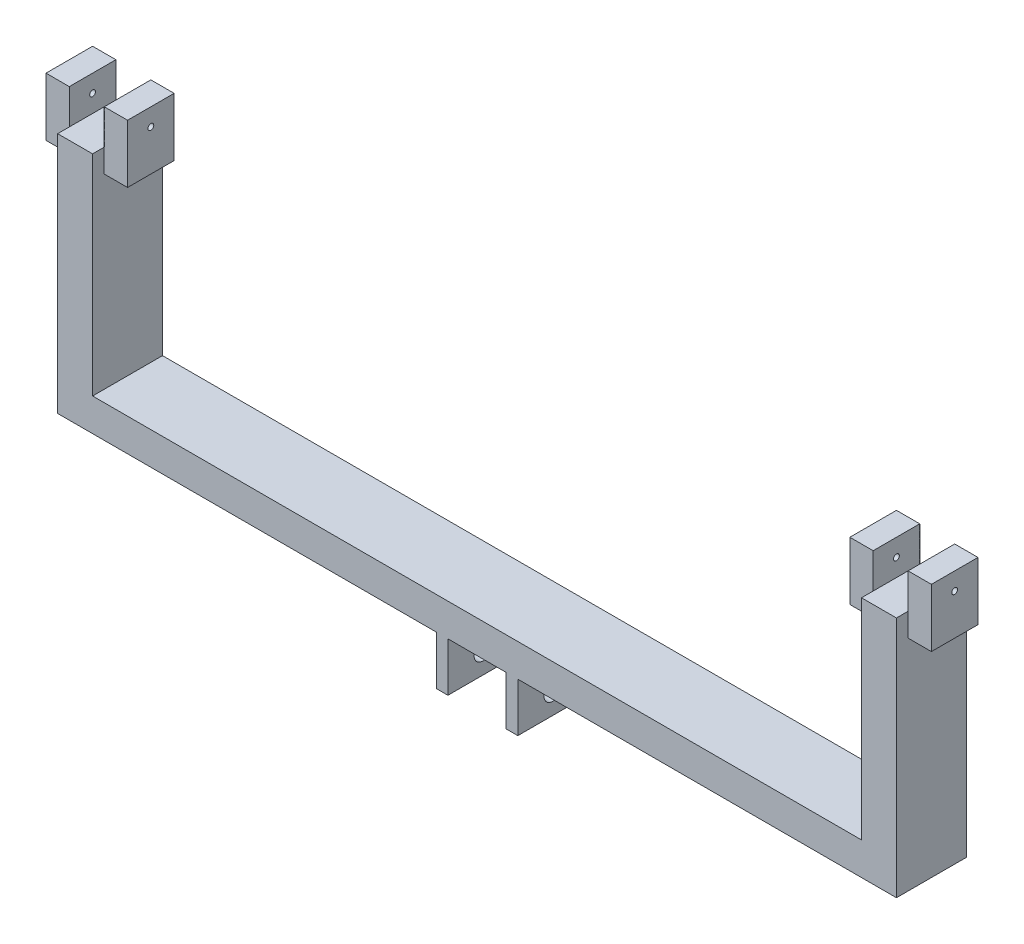
from build123d import *

# Parameters (mm, degrees)
SKETCH1_W            = 177.8
SKETCH1_H            = 177.8
BOSS_EXTRUDE1_DEPTH  = 152.4
SKETCH2_W            = 127
SKETCH2_H            = 106.68
CUT_EXTRUDE1_DEPTH   = 152.4
SKETCH3_R            = 19.05
CUT_EXTRUDE2_DEPTH   = 182.626
SKETCH4_W            = 152.4
SKETCH4_H            = 71.12
BOSS_EXTRUDE2_DEPTH  = 825.5
SKETCH5_W            = 152.4
SKETCH5_H            = 71.12
BOSS_EXTRUDE3_DEPTH  = 825.5
SKETCH6_W            = 76.2
SKETCH6_H            = 152.4
BOSS_EXTRUDE4_DEPTH  = 457.2
SKETCH7_W            = 101.6
SKETCH7_H            = 50.8
BOSS_EXTRUDE9_DEPTH  = 50.8
SKETCH12_W           = 101.6
SKETCH12_H           = 50.8
BOSS_EXTRUDE10_DEPTH = 50.8
SKETCH13_W           = 101.6
SKETCH13_H           = 50.8
BOSS_EXTRUDE11_DEPTH = 50.8
SKETCH14_W           = 101.6
SKETCH14_H           = 50.8
BOSS_EXTRUDE12_DEPTH = 50.8
SKETCH15_W           = 50.8
SKETCH15_H           = 101.6
BOSS_EXTRUDE13_DEPTH = 76.2
SKETCH16_W           = 50.8
SKETCH16_H           = 101.6
BOSS_EXTRUDE14_DEPTH = 76.2
SKETCH17_R           = 6.35
CUT_EXTRUDE3_DEPTH   = 205.994
SKETCH18_R           = 6.35
CUT_EXTRUDE4_DEPTH   = 205.994


with BuildPart() as part:
    # Sketch1 → Boss-Extrude1 (new body)
    with BuildSketch(Plane.XY):
        with Locations((88.9, 88.9)):
            Rectangle(SKETCH1_W, SKETCH1_H)
    extrude(amount=BOSS_EXTRUDE1_DEPTH)

    # Sketch2 → Cut-Extrude1 (cut)
    with BuildSketch(Plane.XY.offset(152.4)):
        with Locations((88.9, 53.34)):
            Rectangle(SKETCH2_W, SKETCH2_H)
    extrude(amount=-CUT_EXTRUDE1_DEPTH, mode=Mode.SUBTRACT)

    # Sketch3 → Cut-Extrude2 (cut)
    with BuildSketch(Plane(origin=(177.8, 0, 0), x_dir=(0, 0, -1), z_dir=(1, 0, 0))):
        with Locations((-76.2, 45.72)):
            Circle(SKETCH3_R)
    extrude(amount=-CUT_EXTRUDE2_DEPTH, mode=Mode.SUBTRACT)

    # Sketch4 → Boss-Extrude2 (add)
    with BuildSketch(Plane(origin=(177.8, 0, 0), x_dir=(0, 0, -1), z_dir=(1, 0, 0))):
        with Locations((-76.2, 142.24)):
            Rectangle(SKETCH4_W, SKETCH4_H)
    extrude(amount=BOSS_EXTRUDE2_DEPTH)

    # Sketch5 → Boss-Extrude3 (add)
    with BuildSketch(Plane.ZY):
        with Locations((76.2, 142.24)):
            Rectangle(SKETCH5_W, SKETCH5_H)
    extrude(amount=BOSS_EXTRUDE3_DEPTH)

    # Sketch6 → Boss-Extrude4 (add)
    with BuildSketch(Plane(origin=(0, 177.8, 0), x_dir=(1, 0, 0), z_dir=(0, 1, 0))):
        with Locations((-787.4, -76.2)):
            Rectangle(SKETCH6_W, SKETCH6_H)
        with Locations((965.2, -76.2)):
            Rectangle(SKETCH6_W, SKETCH6_H)
    extrude(amount=BOSS_EXTRUDE4_DEPTH)

    # Sketch7 → Boss-Extrude9 (add)
    with BuildSketch(Plane.ZY.offset(825.5)):
        with Locations((76.2, 609.6)):
            Rectangle(SKETCH7_W, SKETCH7_H)
    extrude(amount=BOSS_EXTRUDE9_DEPTH)

    # Sketch12 → Boss-Extrude10 (add)
    with BuildSketch(Plane(origin=(-749.3, 0, 0), x_dir=(0, 0, -1), z_dir=(1, 0, 0))):
        with Locations((-76.2, 609.6)):
            Rectangle(SKETCH12_W, SKETCH12_H)
    extrude(amount=BOSS_EXTRUDE10_DEPTH)

    # Sketch13 → Boss-Extrude11 (add)
    with BuildSketch(Plane.ZY.offset(-927.1)):
        with Locations((76.2, 609.6)):
            Rectangle(SKETCH13_W, SKETCH13_H)
    extrude(amount=BOSS_EXTRUDE11_DEPTH)

    # Sketch14 → Boss-Extrude12 (add)
    with BuildSketch(Plane(origin=(1003.3, 0, 0), x_dir=(0, 0, -1), z_dir=(1, 0, 0))):
        with Locations((-76.2, 609.6)):
            Rectangle(SKETCH14_W, SKETCH14_H)
    extrude(amount=BOSS_EXTRUDE12_DEPTH)

    # Sketch15 → Boss-Extrude13 (add)
    with BuildSketch(Plane(origin=(0, 635, 0), x_dir=(1, 0, 0), z_dir=(0, 1, 0))):
        with Locations((901.7, -76.2)):
            Rectangle(SKETCH15_W, SKETCH15_H)
        with Locations((1028.7, -76.2)):
            Rectangle(SKETCH15_W, SKETCH15_H)
    extrude(amount=BOSS_EXTRUDE13_DEPTH)

    # Sketch16 → Boss-Extrude14 (add)
    with BuildSketch(Plane(origin=(0, 635, 0), x_dir=(1, 0, 0), z_dir=(0, 1, 0))):
        with Locations((-723.9, -76.2)):
            Rectangle(SKETCH16_W, SKETCH16_H)
        with Locations((-850.9, -76.2)):
            Rectangle(SKETCH16_W, SKETCH16_H)
    extrude(amount=BOSS_EXTRUDE14_DEPTH)

    # Sketch17 → Cut-Extrude3 (cut)
    with BuildSketch(Plane.ZY.offset(876.3)):
        with Locations((76.2, 673.1)):
            Circle(SKETCH17_R)
    extrude(amount=-CUT_EXTRUDE3_DEPTH, mode=Mode.SUBTRACT)

    # Sketch18 → Cut-Extrude4 (cut)
    with BuildSketch(Plane(origin=(1054.1, 0, 0), x_dir=(0, 0, -1), z_dir=(1, 0, 0))):
        with Locations((-76.2, 673.1)):
            Circle(SKETCH18_R)
    extrude(amount=-CUT_EXTRUDE4_DEPTH, mode=Mode.SUBTRACT)


solid = part.part
